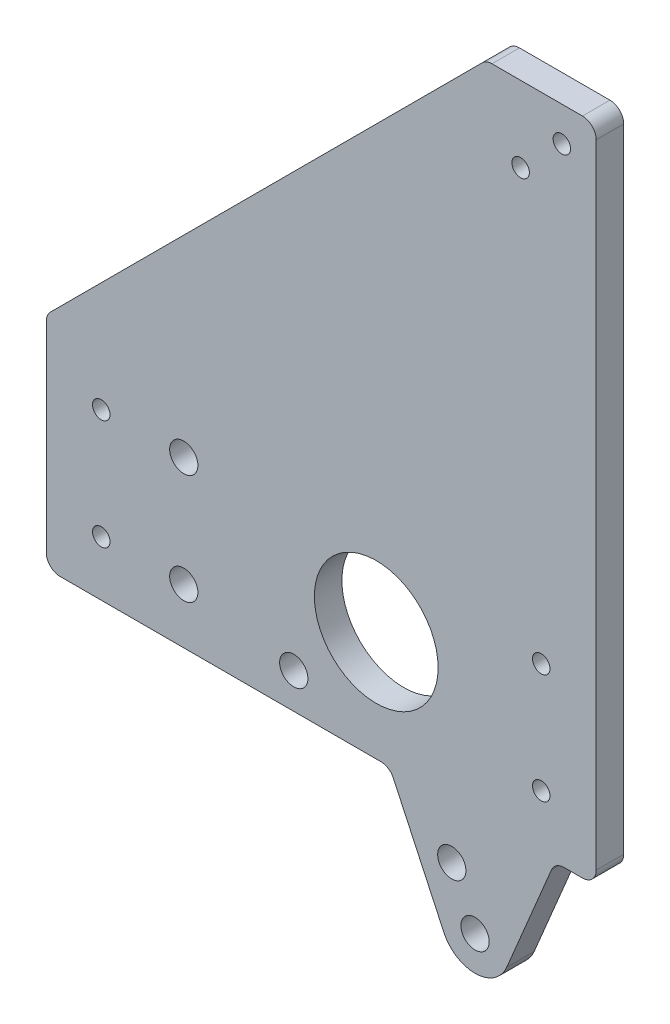
from build123d import *

# Parameters (mm, degrees)
SKETCH1_R                = 3.2639
BOSS_EXTRUDE1_DEPTH      = 6.35
SKETCH2_R                = 2.0193
CUT_EXTRUDE1_DEPTH       = 6.35
SKETCH3_R                = 2.0193
CUT_EXTRUDE2_DEPTH       = 6.35
SKETCH5_R                = 2.0193
CUT_EXTRUDE3_DEPTH       = 6.35
SKETCH6_R                = 14.2875
CUT_EXTRUDE4_DEPTH       = 7.35
SKETCH7_R                = 3.2639
CUT_EXTRUDE5_DEPTH       = 7.35
F_0_257_DIAMETER_HOLE1_D = 6.5278
FILLET1_R                = 3.175
FILLET2_R                = 3.175


with BuildPart() as part:
    # Sketch1 → Boss-Extrude1 (new body)
    with BuildSketch(Plane.XY):
        with BuildLine():
            Line((-12.7, 76.2), (12.7, 76.2))
            Line((12.7, 76.2), (12.7, -76.2))
            Line((12.7, -76.2), (3.175, -76.2))
            Line((3.175, -76.2), (-7.968733256, -102.786346034))
            ThreePointArc((-7.968733256, -102.786346034), (-15.132721636, -107.653920671), (-22.482997382, -103.072495258))
            Line((-22.482997382, -103.072495258), (-35.013847715, -76.2))
            Line((-35.013847715, -76.2), (-114.3, -76.2))
            Line((-114.3, -76.2), (-114.3, -25.4))
            Line((-114.3, -25.4), (-12.7, 76.2))
        make_face()
        with Locations((-15.289179323, -99.717962805)):
            Circle(SKETCH1_R, mode=Mode.SUBTRACT)
        with Locations((-20.656431247, -88.20785391)):
            Circle(SKETCH1_R, mode=Mode.SUBTRACT)
    extrude(amount=BOSS_EXTRUDE1_DEPTH)

    # Sketch2 → Cut-Extrude1 (cut)
    with BuildSketch(Plane.XY.offset(6.35)):
        with Locations((4.7625, 68.2625)):
            Circle(SKETCH2_R)
        with Locations((-4.7625, 58.7375)):
            Circle(SKETCH2_R)
    extrude(amount=-CUT_EXTRUDE1_DEPTH, mode=Mode.SUBTRACT)

    # Sketch3 → Cut-Extrude2 (cut)
    with BuildSketch(Plane.XY.offset(6.35)):
        with Locations((0, -63.5)):
            Circle(SKETCH3_R)
        with Locations((0, -38.1)):
            Circle(SKETCH3_R)
    extrude(amount=-CUT_EXTRUDE2_DEPTH, mode=Mode.SUBTRACT)

    # Sketch5 → Cut-Extrude3 (cut)
    with BuildSketch(Plane.XY.offset(6.35)):
        with Locations((-101.6, -63.5)):
            Circle(SKETCH5_R)
        with Locations((-101.6, -38.1)):
            Circle(SKETCH5_R)
    extrude(amount=-CUT_EXTRUDE3_DEPTH, mode=Mode.SUBTRACT)

    # Sketch6 → Cut-Extrude4 (cut, through all)
    with BuildSketch(Plane.XY.offset(6.35)):
        with Locations((-38.1, -50.8)):
            Circle(SKETCH6_R)
    extrude(amount=-CUT_EXTRUDE4_DEPTH, mode=Mode.SUBTRACT)

    # Sketch7 → Cut-Extrude5 (cut, through all)
    with BuildSketch(Plane.XY.offset(6.35)):
        with Locations((-57.15, -68.0339)):
            Circle(SKETCH7_R)
    extrude(amount=-CUT_EXTRUDE5_DEPTH, mode=Mode.SUBTRACT)

    # F (0.257) Diameter Hole1 (through all)
    with Locations(Plane.XY.offset(6.35)):
        with Locations((-82.55, -38.1), (-82.55, -63.5)):
            Hole(F_0_257_DIAMETER_HOLE1_D / 2)

    # Fillet1
    fillet1_edges = [part.edges().sort_by_distance(p)[0] for p in [
        (12.7, -76.2, 3.175),
        (3.175, -76.2, 3.175),
        (-35.013847715, -76.2, 3.175),
    ]]
    fillet(fillet1_edges, radius=FILLET1_R)

    # Fillet2
    fillet2_edges = [part.edges().sort_by_distance(p)[0] for p in [
        (-114.3, -76.2, 3.175),
        (-114.3, -25.4, 3.175),
        (-12.7, 76.2, 3.175),
        (12.7, 76.2, 3.175),
    ]]
    fillet(fillet2_edges, radius=FILLET2_R)


solid = part.part
